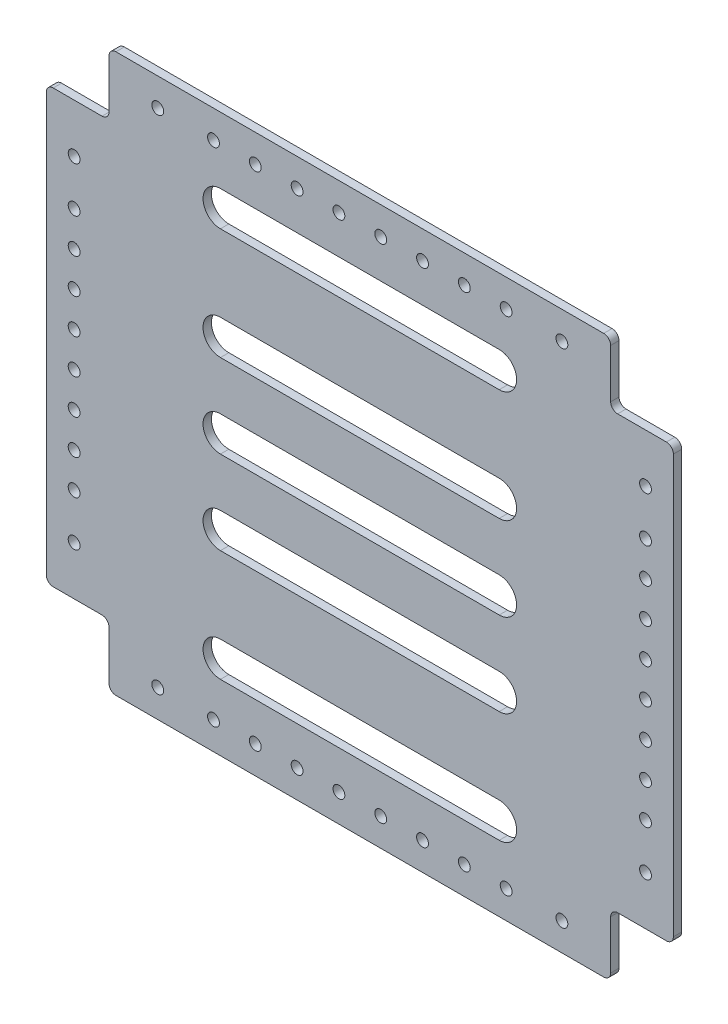
from build123d import *

# Parameters (mm, degrees)
SKETCH_1_W          = 450
SKETCH_1_H          = 400
EXTRUDE_1_DEPTH     = 6
SKETCH_3_R          = 3.75
SKETCH_3_R_2        = 4.25
CUT_EXTRUDE_2_DEPTH = 50
CUT_EXTRUDE_3_DEPTH = 50
SKETCH_5_W          = 45
SKETCH_5_H          = 45
CUT_EXTRUDE_4_DEPTH = 56
FILLET_1_R          = 5
SKETCH_6_R          = 4.25
CUT_EXTRUDE_5_DEPTH = 90


with BuildPart() as part:
    # 草图1 → 凸台-拉伸1 (new body)
    with BuildSketch(Plane.XY):
        Rectangle(SKETCH_1_W, SKETCH_1_H)
    extrude(amount=EXTRUDE_1_DEPTH)

    # 草图3 → 切除-拉伸2 (cut)
    with BuildSketch(Plane.XY.offset(6)):
        with Locations((205, -180)):
            Circle(SKETCH_3_R)
        with Locations((205, -120)):
            Circle(SKETCH_3_R_2)
        with Locations((145, -180)):
            Circle(SKETCH_3_R_2)
        with Locations((145, 180)):
            Circle(SKETCH_3_R_2)
        with Locations((205, 120)):
            Circle(SKETCH_3_R_2)
        with Locations((205, 180)):
            Circle(SKETCH_3_R)
        with Locations((-205, 180)):
            Circle(SKETCH_3_R)
        with Locations((-205, 120)):
            Circle(SKETCH_3_R_2)
        with Locations((-145, 180)):
            Circle(SKETCH_3_R_2)
        with Locations((-145, -180)):
            Circle(SKETCH_3_R_2)
        with Locations((-205, -120)):
            Circle(SKETCH_3_R_2)
        with Locations((-205, -180)):
            Circle(SKETCH_3_R)
    extrude(amount=-CUT_EXTRUDE_2_DEPTH, mode=Mode.SUBTRACT)

    # 草图4 → 切除-拉伸3 (cut)
    with BuildSketch(Plane.XY.offset(6)):
        with BuildLine():
            Line((100, -12.5), (-100, -12.5))
            ThreePointArc((-100, -12.5), (-112.5, 0), (-100, 12.5))
            Line((-100, 12.5), (100, 12.5))
            ThreePointArc((100, 12.5), (112.5, 0), (100, -12.5))
        make_face()
        with BuildLine():
            Line((100, 47.5), (-100, 47.5))
            ThreePointArc((-100, 47.5), (-112.5, 60), (-100, 72.5))
            Line((-100, 72.5), (100, 72.5))
            ThreePointArc((100, 72.5), (112.5, 60), (100, 47.5))
        make_face()
        with BuildLine():
            Line((100, -47.5), (-100, -47.5))
            ThreePointArc((-100, -47.5), (-112.5, -60), (-100, -72.5))
            Line((-100, -72.5), (100, -72.5))
            ThreePointArc((100, -72.5), (112.5, -60), (100, -47.5))
        make_face()
        with BuildLine():
            Line((100, 127.5), (-100, 127.5))
            ThreePointArc((-100, 127.5), (-112.5, 140), (-100, 152.5))
            Line((-100, 152.5), (100, 152.5))
            ThreePointArc((100, 152.5), (112.5, 140), (100, 127.5))
        make_face()
        with BuildLine():
            Line((100, -127.5), (-100, -127.5))
            ThreePointArc((-100, -127.5), (-112.5, -140), (-100, -152.5))
            Line((-100, -152.5), (100, -152.5))
            ThreePointArc((100, -152.5), (112.5, -140), (100, -127.5))
        make_face()
    extrude(amount=-CUT_EXTRUDE_3_DEPTH, mode=Mode.SUBTRACT)

    # 草图5 → 切除-拉伸4 (cut)
    with BuildSketch(Plane.XY.offset(6)):
        with Locations((202.5, -177.5)):
            Rectangle(SKETCH_5_W, SKETCH_5_H)
        with Locations((-202.5, -177.5)):
            Rectangle(SKETCH_5_W, SKETCH_5_H)
        with Locations((-202.5, 177.5)):
            Rectangle(SKETCH_5_W, SKETCH_5_H)
        with Locations((202.5, 177.5)):
            Rectangle(SKETCH_5_W, SKETCH_5_H)
    extrude(amount=-CUT_EXTRUDE_4_DEPTH, mode=Mode.SUBTRACT)

    # 圆角1
    fillet_1_edges = [part.edges().sort_by_distance(p)[0] for p in [
        (180, 200, 3),
        (225, 155, 3),
        (180, 155, 3),
        (-225, 155, 3),
        (-180, 200, 3),
        (-180, 155, 3),
        (-180, -200, 3),
        (-225, -155, 3),
        (-180, -155, 3),
        (225, -155, 3),
        (180, -200, 3),
        (180, -155, 3),
    ]]
    fillet(fillet_1_edges, radius=FILLET_1_R)

    # 草图6 → 切除-拉伸5 (cut)
    with BuildSketch(Plane(origin=(0, 0, 0), x_dir=(-1, 0, 0), z_dir=(0, 0, -1))):
        with Locations((15, -180)):
            Circle(SKETCH_6_R)
        with Locations((45, -180)):
            Circle(SKETCH_6_R)
        with Locations((75, -180)):
            Circle(SKETCH_6_R)
        with Locations((105, -180)):
            Circle(SKETCH_6_R)
        with Locations((-105, -180)):
            Circle(SKETCH_6_R)
        with Locations((-75, -180)):
            Circle(SKETCH_6_R)
        with Locations((-45, -180)):
            Circle(SKETCH_6_R)
        with Locations((-15, -180)):
            Circle(SKETCH_6_R)
        with Locations((-15, 180)):
            Circle(SKETCH_6_R)
        with Locations((-45, 180)):
            Circle(SKETCH_6_R)
        with Locations((-75, 180)):
            Circle(SKETCH_6_R)
        with Locations((-105, 180)):
            Circle(SKETCH_6_R)
        with Locations((105, 180)):
            Circle(SKETCH_6_R)
        with Locations((75, 180)):
            Circle(SKETCH_6_R)
        with Locations((45, 180)):
            Circle(SKETCH_6_R)
        with Locations((15, 180)):
            Circle(SKETCH_6_R)
        with Locations((-205, -12.5)):
            Circle(SKETCH_6_R)
        with Locations((-205, -37.5)):
            Circle(SKETCH_6_R)
        with Locations((-205, -62.5)):
            Circle(SKETCH_6_R)
        with Locations((-205, -87.5)):
            Circle(SKETCH_6_R)
        with Locations((-205, 87.5)):
            Circle(SKETCH_6_R)
        with Locations((-205, 62.5)):
            Circle(SKETCH_6_R)
        with Locations((-205, 37.5)):
            Circle(SKETCH_6_R)
        with Locations((-205, 12.5)):
            Circle(SKETCH_6_R)
        with Locations((205, 12.5)):
            Circle(SKETCH_6_R)
        with Locations((205, 37.5)):
            Circle(SKETCH_6_R)
        with Locations((205, 62.5)):
            Circle(SKETCH_6_R)
        with Locations((205, 87.5)):
            Circle(SKETCH_6_R)
        with Locations((205, -87.5)):
            Circle(SKETCH_6_R)
        with Locations((205, -62.5)):
            Circle(SKETCH_6_R)
        with Locations((205, -37.5)):
            Circle(SKETCH_6_R)
        with Locations((205, -12.5)):
            Circle(SKETCH_6_R)
    extrude(amount=-CUT_EXTRUDE_5_DEPTH, mode=Mode.SUBTRACT)


solid = part.part
